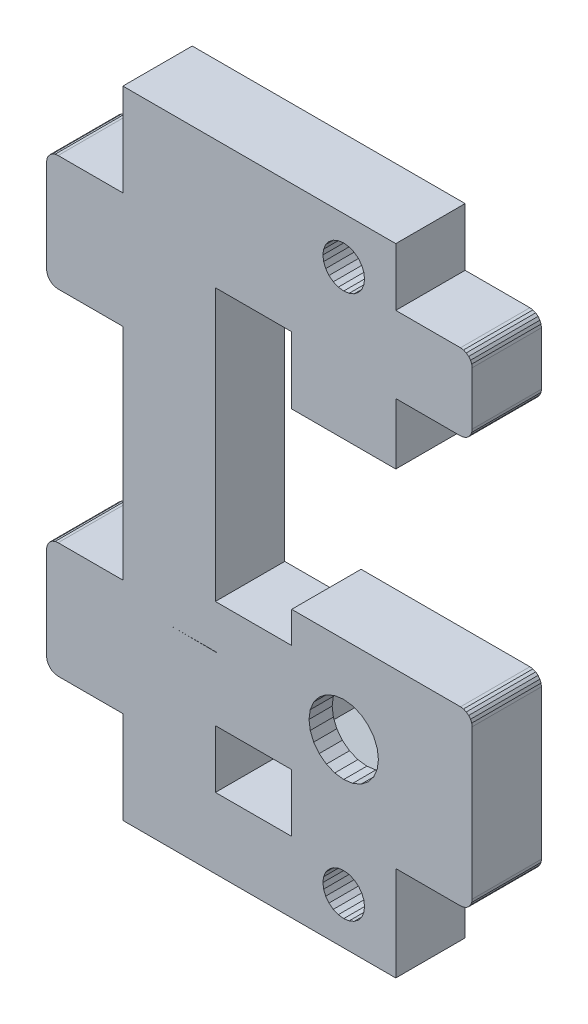
from build123d import *

# Parameters (mm, degrees)
BOSS_EXTRUDE1_DEPTH = 6
BOSS_EXTRUDE2_DEPTH = 2


with BuildPart() as part:
    # Sketch1 → Boss-Extrude1 (new body)
    with BuildSketch(Plane.XY):
        Polygon((-293.236244564, -121.556720051), (-293.336144986, -121.315539097), (-293.495063609, -121.108432315), (-293.70217039, -120.949513693), (-293.943351345, -120.84961327), (-294.20217039, -120.815539097), (-308.80217039, -120.815539097), (-308.80217039, -123.527814521), (-315.40217039, -123.527814521), (-315.40217039, -100.027814521), (-308.80217039, -100.027814521), (-308.80217039, -105.810350932), (-299.80217039, -105.810350932), (-299.80217039, -100.527814521), (-294.20217039, -100.527814521), (-293.943351345, -100.493740347), (-293.70217039, -100.393839924), (-293.495063609, -100.234921302), (-293.336144986, -100.027814521), (-293.236244564, -99.786633566), (-293.20217039, -99.527814521), (-293.20217039, -94.927814521), (-293.236244564, -94.668995475), (-293.336144986, -94.427814521), (-293.495063609, -94.220707739), (-293.70217039, -94.061789117), (-293.943351345, -93.961888694), (-294.20217039, -93.927814521), (-299.80217039, -93.927814521), (-299.80217039, -88.927814521), (-323.40217039, -88.927814521), (-323.40217039, -96.927814521), (-329.00217039, -96.927814521), (-329.260989435, -96.961888694), (-329.50217039, -97.061789117), (-329.709277171, -97.220707739), (-329.868195794, -97.427814521), (-329.968096216, -97.668995475), (-330.00217039, -97.927814521), (-330.00217039, -105.927814521), (-329.968096216, -106.186633566), (-329.868195794, -106.427814521), (-329.709277171, -106.634921302), (-329.50217039, -106.793839924), (-329.260989435, -106.893740347), (-329.00217039, -106.927814521), (-323.40217039, -106.927814521), (-323.40217039, -125.927814521), (-329.00217039, -125.927814521), (-329.260989435, -125.961888694), (-329.50217039, -126.061789117), (-329.709277171, -126.220707739), (-329.868195794, -126.427814521), (-329.968096216, -126.668995475), (-330.00217039, -126.927814521), (-330.00217039, -134.927814521), (-329.968096216, -135.186633566), (-329.868195794, -135.427814521), (-329.709277171, -135.634921302), (-329.50217039, -135.793839924), (-329.260989435, -135.893740347), (-329.00217039, -135.927814521), (-323.40217039, -135.927814521), (-323.40217039, -143.927814521), (-299.80217039, -143.927814521), (-299.80217039, -135.727814521), (-294.20217039, -135.727814521), (-293.943351345, -135.693740347), (-293.70217039, -135.593839924), (-293.495063609, -135.434921302), (-293.336144986, -135.227814521), (-293.236244564, -134.986633566), (-293.20217039, -134.727814521), (-293.20217039, -121.815539097), align=None)
        Polygon((-302.743324663, -140.827814521), (-302.563503903, -140.393688802), (-302.50217039, -139.927814521), (-302.563503903, -139.461940239), (-302.743324663, -139.027814521), (-303.029378184, -138.655022314), (-303.40217039, -138.368968794), (-303.836296109, -138.189148033), (-304.30217039, -138.127814521), (-304.768044671, -138.189148033), (-305.20217039, -138.368968794), (-305.574962596, -138.655022314), (-305.861016117, -139.027814521), (-306.040836877, -139.461940239), (-306.10217039, -139.927814521), (-306.040836877, -140.393688802), (-305.861016117, -140.827814521), (-305.574962596, -141.200606727), (-305.20217039, -141.486660247), (-304.768044671, -141.666481008), (-304.30217039, -141.727814521), (-303.836296109, -141.666481008), (-303.40217039, -141.486660247), (-303.029378184, -141.200606727), align=None, mode=Mode.SUBTRACT)
        Polygon((-305.861016117, -93.827814521), (-305.574962596, -94.200606727), (-305.20217039, -94.486660247), (-304.768044671, -94.666481008), (-304.30217039, -94.727814521), (-303.836296109, -94.666481008), (-303.40217039, -94.486660247), (-303.029378184, -94.200606727), (-302.743324663, -93.827814521), (-302.563503903, -93.393688802), (-302.50217039, -92.927814521), (-302.563503903, -92.461940239), (-302.743324663, -92.027814521), (-303.029378184, -91.655022314), (-303.40217039, -91.368968794), (-303.836296109, -91.189148033), (-304.30217039, -91.127814521), (-304.768044671, -91.189148033), (-305.20217039, -91.368968794), (-305.574962596, -91.655022314), (-305.861016117, -92.027814521), (-306.040836877, -92.461940239), (-306.10217039, -92.927814521), (-306.040836877, -93.393688802), align=None, mode=Mode.SUBTRACT)
        Polygon((-315.40217039, -132.827814521), (-315.398235108, -137.827812972), (-308.79823715, -137.822621096), (-308.80217039, -132.822622643), align=None, mode=Mode.SUBTRACT)
        Polygon((-308.80217039, -130.908427143), (-304.30217039, -133.506503354), (-299.80217039, -130.908427143), (-299.80217039, -125.71227472), (-304.30217039, -123.114198509), (-308.80217039, -125.71227472), align=None, mode=Mode.SUBTRACT)
        Polygon((-315.359812177, -127.280109863), (-315.263602907, -127.300206805), (-319.168644113, -127.280109863), align=None, mode=Mode.SUBTRACT)
    extrude(amount=-BOSS_EXTRUDE1_DEPTH)

    # Sketch1_3 → Boss-Extrude2 (add)
    with BuildSketch(Plane.XY):
        Polygon((-304.30217039, -123.114198509), (-308.80217039, -125.71227472), (-308.80217039, -130.908427143), (-304.30217039, -133.506503354), (-299.80217039, -130.908427143), (-299.80217039, -125.71227472), align=None)
        Polygon((-308.60217039, -130.792957089), (-304.30217039, -133.275563247), (-300.00217039, -130.792957089), (-300.00217039, -125.827744774), (-304.30217039, -123.345138617), (-308.60217039, -125.827744774), align=None, mode=Mode.SUBTRACT)
        Polygon((-308.60217039, -125.827744774), (-308.60217039, -130.792957089), (-304.30217039, -133.275563247), (-300.00217039, -130.792957089), (-300.00217039, -125.827744774), (-304.30217039, -123.345138617), align=None)
        Polygon((-304.30217039, -123.576078724), (-308.40217039, -125.943214828), (-308.40217039, -130.677487035), (-304.30217039, -133.044623139), (-300.20217039, -130.677487035), (-300.20217039, -125.943214828), align=None, mode=Mode.SUBTRACT)
        Polygon((-300.20217039, -125.943214828), (-304.30217039, -123.576078724), (-308.40217039, -125.943214828), (-308.40217039, -130.677487035), (-304.30217039, -133.044623139), (-300.20217039, -130.677487035), align=None)
        Polygon((-300.40217039, -126.058684882), (-304.30217039, -123.807018832), (-308.20217039, -126.058684882), (-308.20217039, -130.562016981), (-304.30217039, -132.813683031), (-300.40217039, -130.562016981), align=None, mode=Mode.SUBTRACT)
        Polygon((-300.40217039, -130.562016981), (-300.40217039, -126.058684882), (-304.30217039, -123.807018832), (-308.20217039, -126.058684882), (-308.20217039, -130.562016981), (-304.30217039, -132.813683031), align=None)
        Polygon((-300.60217039, -126.174154936), (-304.30217039, -124.03795894), (-308.00217039, -126.174154936), (-308.00217039, -130.446546928), (-304.30217039, -132.582742924), (-300.60217039, -130.446546928), align=None, mode=Mode.SUBTRACT)
        Polygon((-300.60217039, -130.446546928), (-300.60217039, -126.174154936), (-304.30217039, -124.03795894), (-308.00217039, -126.174154936), (-308.00217039, -130.446546928), (-304.30217039, -132.582742924), align=None)
        Polygon((-307.80217039, -130.331076874), (-304.30217039, -132.351802816), (-300.80217039, -130.331076874), (-300.80217039, -126.289624989), (-304.30217039, -124.268899047), (-307.80217039, -126.289624989), align=None, mode=Mode.SUBTRACT)
        Polygon((-307.80217039, -126.289624989), (-307.80217039, -130.331076874), (-304.30217039, -132.351802816), (-300.80217039, -130.331076874), (-300.80217039, -126.289624989), (-304.30217039, -124.268899047), align=None)
        Polygon((-301.00217039, -126.405095043), (-304.30217039, -124.499839155), (-307.60217039, -126.405095043), (-307.60217039, -130.21560682), (-304.30217039, -132.120862708), (-301.00217039, -130.21560682), align=None, mode=Mode.SUBTRACT)
        Polygon((-301.00217039, -130.21560682), (-301.00217039, -126.405095043), (-304.30217039, -124.499839155), (-307.60217039, -126.405095043), (-307.60217039, -130.21560682), (-304.30217039, -132.120862708), align=None)
        Polygon((-307.40217039, -130.100136766), (-304.30217039, -131.889922601), (-301.20217039, -130.100136766), (-301.20217039, -126.520565097), (-304.30217039, -124.730779263), (-307.40217039, -126.520565097), align=None, mode=Mode.SUBTRACT)
        Polygon((-307.40217039, -126.520565097), (-307.40217039, -130.100136766), (-304.30217039, -131.889922601), (-301.20217039, -130.100136766), (-301.20217039, -126.520565097), (-304.30217039, -124.730779263), align=None)
        Polygon((-302.180850046, -130.431671275), (-301.704094179, -129.810350932), (-301.404392911, -129.086808067), (-301.30217039, -128.310350932), (-301.404392911, -127.533893796), (-301.704094179, -126.810350932), (-302.180850046, -126.189030588), (-302.80217039, -125.71227472), (-303.525713255, -125.412573453), (-304.30217039, -125.310350932), (-305.078627525, -125.412573453), (-305.80217039, -125.71227472), (-306.423490733, -126.189030588), (-306.900246601, -126.810350932), (-307.199947869, -127.533893796), (-307.30217039, -128.310350932), (-307.199947869, -129.086808067), (-306.900246601, -129.810350932), (-306.423490733, -130.431671275), (-305.80217039, -130.908427143), (-305.078627525, -131.208128411), (-304.30217039, -131.310350932), (-303.525713255, -131.208128411), (-302.80217039, -130.908427143), align=None, mode=Mode.SUBTRACT)
    extrude(amount=-BOSS_EXTRUDE2_DEPTH)


solid = part.part
